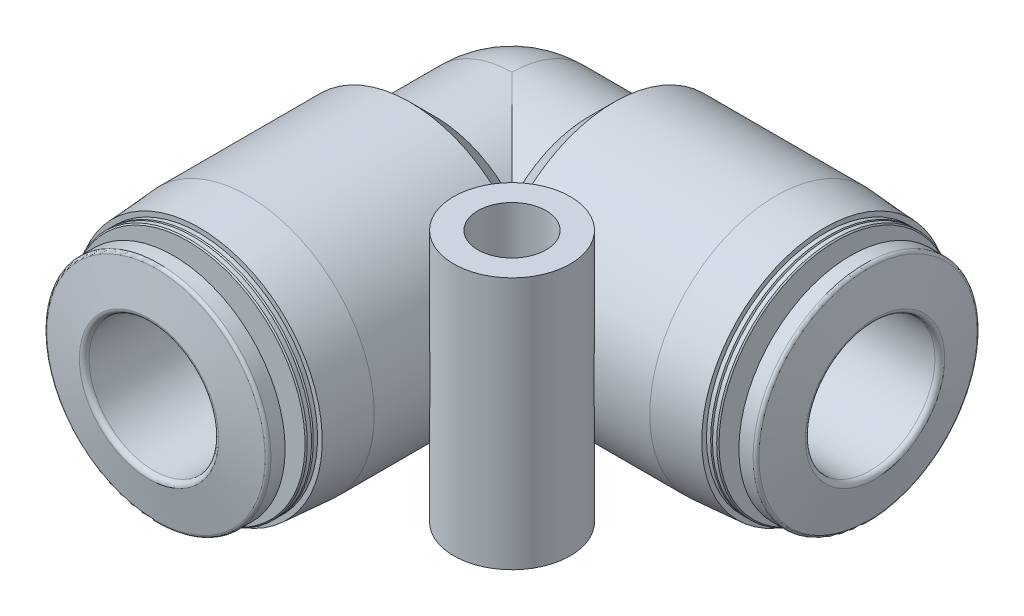
from build123d import *
from build123d.topology import SkipClean

# Parameters (mm, degrees)
AUFSATZ_LINEAR_AUSTRAGEN1_DEPTH      = 6.3
AUFSATZ_LINEAR_AUSTRAGEN2_DEPTH      = 6.3
ROTATION3_ANGLE                      = 90
SKIZZE6_W                            = 12
SKIZZE6_H                            = 12
AUFSATZ_LINEAR_AUSTRAGEN3_DEPTH      = 1
AUFSATZ_LINEAR_AUSTRAGEN3_DEPTH_BACK = 1
SKIZZE7_W                            = 3.6
SKIZZE7_H                            = 15.6
BOHRUNG1_D                           = 4.2


with BuildPart() as part:
    # Skizze1 → Rotation1 (revolve)
    with BuildSketch(Plane.XY, mode=Mode.PRIVATE) as rotation1_sk:
        with BuildLine():
            Line((0, 6.24), (4.74, 6.24))
            Line((4.74, 6.24), (6.3, 7.8))
            Line((6.3, 7.8), (16.3, 7.8))
            Line((16.3, 7.8), (19.3, 7.59022))
            Line((19.3, 7.59022), (19.3, 7.3))
            Line((19.3, 7.3), (19.55691, 7.3))
            Line((19.55691, 7.3), (19.614645, 7.2))
            Line((19.614645, 7.2), (19.67238, 7.3))
            Line((19.67238, 7.3), (19.929289, 7.3))
            Line((19.929289, 7.3), (20, 7.229289))
            Line((20, 7.229289), (20, 4.7))
            Line((20, 4.7), (20.525, 4.7))
            ThreePointArc((20.525, 4.7), (20.790165, 4.809835), (20.9, 5.075))
            Line((20.9, 5.075), (20.9, 6.9))
            Line((20.9, 6.9), (21.77373, 6.9))
            ThreePointArc((21.77373, 6.9), (21.902287, 6.853209), (21.970691, 6.73473))
            Line((21.970691, 6.73473), (22.4, 4.3))
            Line((22.4, 4.3), (22.4, 0))
            Line((22.4, 0), (-6.24, 0))
            ThreePointArc((-6.24, 0), (-4.412346, 4.412346), (0, 6.24))
        make_face()
    revolve(rotation1_sk.sketch.rotate(Axis((22.4, 0, 0), (-1, 0, 0)), 270), axis=Axis((22.4, 0, 0), (-1, 0, 0)))

    # Skizze2 → Rotation2 (revolve)
    with BuildSketch(Plane(origin=(0, 0, 0), x_dir=(1, 0, 0), z_dir=(0, 1, 0)), mode=Mode.PRIVATE) as rotation2_sk:
        with BuildLine():
            Line((0, 0), (6.24, 0))
            Line((6.24, 0), (6.24, -4.74))
            Line((6.24, -4.74), (7.8, -6.3))
            Line((7.8, -6.3), (7.8, -16.3))
            Line((7.8, -16.3), (7.59022, -19.3))
            Line((7.59022, -19.3), (7.3, -19.3))
            Line((7.3, -19.3), (7.3, -19.55691))
            Line((7.3, -19.55691), (7.2, -19.614645))
            Line((7.2, -19.614645), (7.3, -19.67238))
            Line((7.3, -19.67238), (7.3, -19.929289))
            Line((7.3, -19.929289), (7.229289, -20))
            Line((7.229289, -20), (4.7, -20))
            Line((4.7, -20), (4.7, -20.525))
            ThreePointArc((4.7, -20.525), (4.809835, -20.790165), (5.075, -20.9))
            Line((5.075, -20.9), (6.9, -20.9))
            Line((6.9, -20.9), (6.9, -21.77373))
            ThreePointArc((6.9, -21.77373), (6.853209, -21.902287), (6.73473, -21.970691))
            Line((6.73473, -21.970691), (4.3, -22.4))
            Line((4.3, -22.4), (0, -22.4))
            Line((0, -22.4), (0, 0))
        make_face()
    revolve(rotation2_sk.sketch.rotate(Axis((0, 0, 22.4), (0, 0, -1)), 180), axis=Axis((0, 0, 22.4), (0, 0, -1)))

    # Skizze3 → Aufsatz-Linear austragen1 (add)
    with BuildSketch(Plane(origin=(0, 0, 0), x_dir=(0, 0, -1), z_dir=(1, 0, 0))):
        with BuildLine():
            Line((4.68, 1), (4.68, -1))
            Line((4.68, -1), (7.735632, -1))
            ThreePointArc((7.735632, -1), (7.8, 0), (7.735632, 1))
            Line((7.735632, 1), (4.68, 1))
        make_face()
    extrude(amount=AUFSATZ_LINEAR_AUSTRAGEN1_DEPTH)

    # Skizze4 → Aufsatz-Linear austragen2 (add)
    with SkipClean():  # the faces are left unmerged after this step: merging them gives an invalid solid
        with BuildSketch(Plane.XY):
            with BuildLine():
                Line((-7.735632, -1), (-4.68, -1))
                Line((-4.68, -1), (-4.68, 1))
                Line((-4.68, 1), (-7.735632, 1))
                ThreePointArc((-7.735632, 1), (-7.8, 0), (-7.735632, -1))
            make_face()
        extrude(amount=AUFSATZ_LINEAR_AUSTRAGEN2_DEPTH)

    # Skizze5 → Rotation3 (revolve)
    with SkipClean():  # the faces are left unmerged after this step: merging them gives an invalid solid
        with BuildSketch(Plane.XY):
            with BuildLine():
                Line((-7.735632, -1), (-4.68, -1))
                Line((-4.68, -1), (-4.68, 1))
                Line((-4.68, 1), (-7.735632, 1))
                ThreePointArc((-7.735632, 1), (-7.8, 0), (-7.735632, -1))
            make_face()
        revolve(axis=Axis((0, 1, 0), (0, -1, 0)), revolution_arc=ROTATION3_ANGLE)

    # Skizze6 → Aufsatz-Linear austragen3 (add, two sides)
    with SkipClean():  # the faces are left unmerged after this step: merging them gives an invalid solid
        with BuildSketch(Plane(origin=(0, 0, 0), x_dir=(1, 0, 0), z_dir=(0, 1, 0))) as aufsatz_linear_austragen3_sk:
            with Locations((6, -6)):
                Rectangle(SKIZZE6_W, SKIZZE6_H)
        extrude(amount=AUFSATZ_LINEAR_AUSTRAGEN3_DEPTH)
        extrude(aufsatz_linear_austragen3_sk.sketch, amount=-AUFSATZ_LINEAR_AUSTRAGEN3_DEPTH_BACK)

    # Skizze7 → Rotation4 (revolve)
    with BuildSketch(Plane.XY.offset(10), mode=Mode.PRIVATE) as rotation4_sk:
        with Locations((11.8, 0)):
            Rectangle(SKIZZE7_W, SKIZZE7_H)
    revolve(rotation4_sk.sketch.rotate(Axis((10, -7.8, 10), (0, 1, 0)), 90), axis=Axis((10, -7.8, 10), (0, 1, 0)))

    # Bohrung1 (through all)
    with Locations(Plane(origin=(0, -7.8, 0), x_dir=(-1, 0, 0), z_dir=(0, -1, 0))):
        with Locations((-10, -10)):
            Hole(BOHRUNG1_D / 2)

    # Skizze10 → Schnitt-Rotation1 (revolve, cut)
    with SkipClean():  # the faces are left unmerged after this step: merging them gives an invalid solid
        with BuildSketch(Plane.XY, mode=Mode.PRIVATE) as schnitt_rotation1_sk:
            with BuildLine():
                Line((0, 2.3), (4.3, 2.3))
                Line((4.3, 2.3), (4.3, 3.8))
                ThreePointArc((4.3, 3.8), (4.358579, 3.941421), (4.5, 4))
                Line((4.5, 4), (22.1, 4))
                ThreePointArc((22.1, 4), (22.312132, 4.087868), (22.4, 4.3))
                Line((22.4, 4.3), (22.4, 0))
                Line((22.4, 0), (-2.3, 0))
                ThreePointArc((-2.3, 0), (-1.626346, 1.626346), (0, 2.3))
            make_face()
        revolve(schnitt_rotation1_sk.sketch.rotate(Axis((22.4, 0, 0), (-1, 0, 0)), 90), axis=Axis((22.4, 0, 0), (-1, 0, 0)), mode=Mode.SUBTRACT)

    # Skizze11 → Schnitt-Rotation2 (revolve, cut)
    with SkipClean():  # the faces are left unmerged after this step: merging them gives an invalid solid
        with BuildSketch(Plane(origin=(0, 0, 0), x_dir=(1, 0, 0), z_dir=(0, 1, 0))):
            with BuildLine():
                Line((0, 0), (2.3, 0))
                Line((2.3, 0), (2.3, -4.3))
                Line((2.3, -4.3), (3.8, -4.3))
                ThreePointArc((3.8, -4.3), (3.941421, -4.358579), (4, -4.5))
                Line((4, -4.5), (4, -22.1))
                ThreePointArc((4, -22.1), (4.087868, -22.312132), (4.3, -22.4))
                Line((4.3, -22.4), (0, -22.4))
                Line((0, -22.4), (0, 0))
            make_face()
        revolve(axis=Axis((0, 0, 22.4), (0, 0, -1)), mode=Mode.SUBTRACT)


solid = part.part
